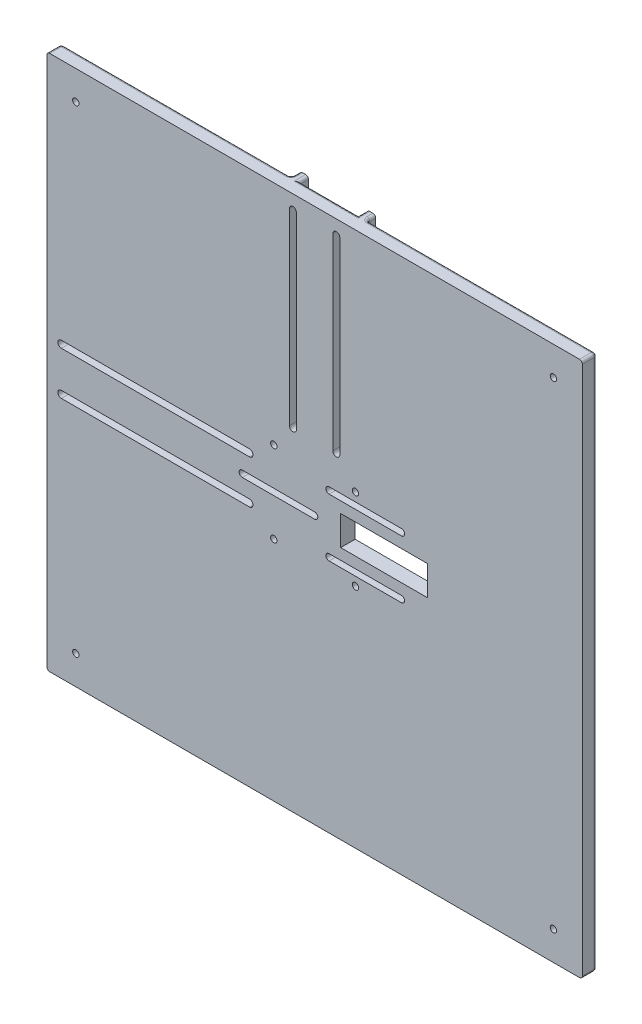
from build123d import *

# Parameters (mm, degrees)
ESQUISSE1_W              = 185
ESQUISSE1_H              = 185
BOSS_EXTRU_1_DEPTH       = 5
ESQUISSE2_W              = 70
ESQUISSE2_H              = 3
ESQUISSE2_W_2            = 3
ESQUISSE2_H_2            = 70
BOSS_EXTRU_2_DEPTH       = 3
CONG_1_R                 = 1
ENL_V_MAT_EXTRU_1_REACH  = 7
ESQUISSE4_R              = 1.1
ENL_V_MAT_EXTRU_2_DEPTH  = 6
ENL_V_MAT_EXTRU_3_REACH  = 7
ENL_V_MAT_EXTRU_5_REACH  = 10
ENL_V_MAT_EXTRU_7_REACH  = 7
ESQUISSE11_W             = 30
ESQUISSE11_H             = 10.2
ESQUISSE12_W             = 31
ESQUISSE12_H             = 4.3
ENL_V_MAT_EXTRU_9_DEPTH  = 2
CONG_2_R                 = 0.5
ENL_V_MAT_EXTRU_10_DEPTH = 3


with BuildPart() as part:
    # Esquisse1 → Boss.-Extru.1 (new body)
    with BuildSketch(Plane.XY):
        Rectangle(ESQUISSE1_W, ESQUISSE1_H)
    extrude(amount=BOSS_EXTRU_1_DEPTH)

    # Esquisse2 → Boss.-Extru.2 (add)
    with BuildSketch(Plane(origin=(0, 0, 0), x_dir=(-1, 0, 0), z_dir=(0, 0, -1))):
        with Locations((57.5, 11.6)):
            Rectangle(ESQUISSE2_W, ESQUISSE2_H)
        with Locations((57.5, -11.6)):
            Rectangle(ESQUISSE2_W, ESQUISSE2_H)
        with Locations((11.6, 57.5)):
            Rectangle(ESQUISSE2_W_2, ESQUISSE2_H_2)
        with Locations((-11.6, 57.5)):
            Rectangle(ESQUISSE2_W_2, ESQUISSE2_H_2)
    extrude(amount=BOSS_EXTRU_2_DEPTH)

    # Congé1
    cong_1_edges = [part.edges().sort_by_distance(p)[0] for p in [
        (0, 92.5, 0),
        (11.6, 22.5, 0),
        (13.1, 22.5, -1.5),
        (10.1, 92.5, -1.5),
        (13.1, 57.5, 0),
        (13.1, 92.5, -1.5),
        (-92.5, 0, 0),
        (-57.5, 13.1, 0),
        (-92.5, 13.1, -1.5),
        (-22.5, 11.6, 0),
        (-22.5, 13.1, -1.5),
        (-92.5, 10.1, -1.5),
        (-92.5, -52.8, 0),
        (-92.5, -13.1, -1.5),
        (-92.5, -10.1, -1.5),
        (-22.5, -11.6, 0),
        (-57.5, -13.1, 0),
        (-22.5, -13.1, -1.5),
        (-52.8, 92.5, 0),
        (-11.6, 22.5, 0),
        (-13.1, 57.5, 0),
        (-13.1, 22.5, -1.5),
        (-13.1, 92.5, -1.5),
        (-10.1, 92.5, -1.5),
        (52.8, 92.5, 0),
        (92.5, 0, 0),
        (0, -92.5, 0),
        (-92.5, 52.8, 0),
        (-92.5, 92.5, 2.5),
        (92.5, 92.5, 2.5),
        (92.5, -92.5, 2.5),
        (-92.5, -92.5, 2.5),
    ]]
    fillet(cong_1_edges, radius=CONG_1_R)

    # Esquisse4 → Enlèv. mat.-Extru.1 (cut, up to next)
    with BuildSketch(Plane(origin=(0, 0, 0), x_dir=(-1, 0, 0), z_dir=(0, 0, -1)), mode=Mode.PRIVATE) as enl_v_mat_extru_1_sk1:
        with Locations((-14.1, 14.1)):
            Circle(ESQUISSE4_R)
    enl_v_mat_extru_1_tool1 = extrude(enl_v_mat_extru_1_sk1.sketch, amount=-ENL_V_MAT_EXTRU_1_REACH, mode=Mode.PRIVATE) & part.part
    add(enl_v_mat_extru_1_tool1.solids().sort_by_distance((14.1, 14.1, 0))[0], mode=Mode.SUBTRACT)
    # Esquisse4 → Enlèv. mat.-Extru.1 (cut, up to next)
    with BuildSketch(Plane(origin=(0, 0, 0), x_dir=(-1, 0, 0), z_dir=(0, 0, -1)), mode=Mode.PRIVATE) as enl_v_mat_extru_1_sk2:
        with Locations((14.1, 14.1)):
            Circle(ESQUISSE4_R)
    enl_v_mat_extru_1_tool2 = extrude(enl_v_mat_extru_1_sk2.sketch, amount=-ENL_V_MAT_EXTRU_1_REACH, mode=Mode.PRIVATE) & part.part
    add(enl_v_mat_extru_1_tool2.solids().sort_by_distance((-14.1, 14.1, 0))[0], mode=Mode.SUBTRACT)
    # Esquisse4 → Enlèv. mat.-Extru.1 (cut, up to next)
    with BuildSketch(Plane(origin=(0, 0, 0), x_dir=(-1, 0, 0), z_dir=(0, 0, -1)), mode=Mode.PRIVATE) as enl_v_mat_extru_1_sk3:
        with Locations((14.1, -14.1)):
            Circle(ESQUISSE4_R)
    enl_v_mat_extru_1_tool3 = extrude(enl_v_mat_extru_1_sk3.sketch, amount=-ENL_V_MAT_EXTRU_1_REACH, mode=Mode.PRIVATE) & part.part
    add(enl_v_mat_extru_1_tool3.solids().sort_by_distance((-14.1, -14.1, 0))[0], mode=Mode.SUBTRACT)
    # Esquisse4 → Enlèv. mat.-Extru.1 (cut, up to next)
    with BuildSketch(Plane(origin=(0, 0, 0), x_dir=(-1, 0, 0), z_dir=(0, 0, -1)), mode=Mode.PRIVATE) as enl_v_mat_extru_1_sk4:
        with Locations((-14.1, -14.1)):
            Circle(ESQUISSE4_R)
    enl_v_mat_extru_1_tool4 = extrude(enl_v_mat_extru_1_sk4.sketch, amount=-ENL_V_MAT_EXTRU_1_REACH, mode=Mode.PRIVATE) & part.part
    add(enl_v_mat_extru_1_tool4.solids().sort_by_distance((14.1, -14.1, 0))[0], mode=Mode.SUBTRACT)
    # Esquisse4 → Enlèv. mat.-Extru.1 (cut, up to next)
    with BuildSketch(Plane(origin=(0, 0, 0), x_dir=(-1, 0, 0), z_dir=(0, 0, -1)), mode=Mode.PRIVATE) as enl_v_mat_extru_1_sk5:
        with Locations((-82.5, -82.5)):
            Circle(ESQUISSE4_R)
    enl_v_mat_extru_1_tool5 = extrude(enl_v_mat_extru_1_sk5.sketch, amount=-ENL_V_MAT_EXTRU_1_REACH, mode=Mode.PRIVATE) & part.part
    add(enl_v_mat_extru_1_tool5.solids().sort_by_distance((82.5, -82.5, 0))[0], mode=Mode.SUBTRACT)
    # Esquisse4 → Enlèv. mat.-Extru.1 (cut, up to next)
    with BuildSketch(Plane(origin=(0, 0, 0), x_dir=(-1, 0, 0), z_dir=(0, 0, -1)), mode=Mode.PRIVATE) as enl_v_mat_extru_1_sk6:
        with Locations((-82.5, 82.5)):
            Circle(ESQUISSE4_R)
    enl_v_mat_extru_1_tool6 = extrude(enl_v_mat_extru_1_sk6.sketch, amount=-ENL_V_MAT_EXTRU_1_REACH, mode=Mode.PRIVATE) & part.part
    add(enl_v_mat_extru_1_tool6.solids().sort_by_distance((82.5, 82.5, 0))[0], mode=Mode.SUBTRACT)
    # Esquisse4 → Enlèv. mat.-Extru.1 (cut, up to next)
    with BuildSketch(Plane(origin=(0, 0, 0), x_dir=(-1, 0, 0), z_dir=(0, 0, -1)), mode=Mode.PRIVATE) as enl_v_mat_extru_1_sk7:
        with Locations((82.5, -82.5)):
            Circle(ESQUISSE4_R)
    enl_v_mat_extru_1_tool7 = extrude(enl_v_mat_extru_1_sk7.sketch, amount=-ENL_V_MAT_EXTRU_1_REACH, mode=Mode.PRIVATE) & part.part
    add(enl_v_mat_extru_1_tool7.solids().sort_by_distance((-82.5, -82.5, 0))[0], mode=Mode.SUBTRACT)
    # Esquisse4 → Enlèv. mat.-Extru.1 (cut, up to next)
    with BuildSketch(Plane(origin=(0, 0, 0), x_dir=(-1, 0, 0), z_dir=(0, 0, -1)), mode=Mode.PRIVATE) as enl_v_mat_extru_1_sk8:
        with Locations((82.5, 82.5)):
            Circle(ESQUISSE4_R)
    enl_v_mat_extru_1_tool8 = extrude(enl_v_mat_extru_1_sk8.sketch, amount=-ENL_V_MAT_EXTRU_1_REACH, mode=Mode.PRIVATE) & part.part
    add(enl_v_mat_extru_1_tool8.solids().sort_by_distance((-82.5, 82.5, 0))[0], mode=Mode.SUBTRACT)

    # Esquisse5 → Enlèv. mat.-Extru.2 (cut, through all)
    with BuildSketch(Plane(origin=(0, 0, 0), x_dir=(-1, 0, 0), z_dir=(0, 0, -1))):
        with BuildLine():
            Line((-6.3, 87.5), (-6.3, 22.5))
            ThreePointArc((-6.3, 22.5), (-7.5, 21.3), (-8.7, 22.5))
            Line((-8.7, 22.5), (-8.7, 87.5))
            ThreePointArc((-8.7, 87.5), (-7.5, 88.7), (-6.3, 87.5))
        make_face()
        with BuildLine():
            Line((8.7, 87.5), (8.7, 22.5))
            ThreePointArc((8.7, 22.5), (7.5, 21.3), (6.3, 22.5))
            Line((6.3, 22.5), (6.3, 87.5))
            ThreePointArc((6.3, 87.5), (7.5, 88.7), (8.7, 87.5))
        make_face()
    extrude(amount=-ENL_V_MAT_EXTRU_2_DEPTH, mode=Mode.SUBTRACT)

    # Esquisse6 → Enlèv. mat.-Extru.3 (cut, up to next)
    with BuildSketch(Plane(origin=(0, 0, 0), x_dir=(-1, 0, 0), z_dir=(0, 0, -1)), mode=Mode.PRIVATE) as enl_v_mat_extru_3_sk1:
        with BuildLine():
            Line((87.5, -8.7), (22.5, -8.7))
            ThreePointArc((22.5, -8.7), (21.3, -7.5), (22.5, -6.3))
            Line((22.5, -6.3), (87.5, -6.3))
            ThreePointArc((87.5, -6.3), (88.7, -7.5), (87.5, -8.7))
        make_face()
    enl_v_mat_extru_3_tool1 = extrude(enl_v_mat_extru_3_sk1.sketch, amount=-ENL_V_MAT_EXTRU_3_REACH, mode=Mode.PRIVATE) & part.part
    add(enl_v_mat_extru_3_tool1.solids().sort_by_distance((-55, -7.5, 0))[0], mode=Mode.SUBTRACT)
    # Esquisse6 → Enlèv. mat.-Extru.3 (cut, up to next)
    with BuildSketch(Plane(origin=(0, 0, 0), x_dir=(-1, 0, 0), z_dir=(0, 0, -1)), mode=Mode.PRIVATE) as enl_v_mat_extru_3_sk2:
        with BuildLine():
            Line((22.5, 8.7), (87.5, 8.7))
            ThreePointArc((87.5, 8.7), (88.7, 7.5), (87.5, 6.3))
            Line((87.5, 6.3), (22.5, 6.3))
            ThreePointArc((22.5, 6.3), (21.3, 7.5), (22.5, 8.7))
        make_face()
    enl_v_mat_extru_3_tool2 = extrude(enl_v_mat_extru_3_sk2.sketch, amount=-ENL_V_MAT_EXTRU_3_REACH, mode=Mode.PRIVATE) & part.part
    add(enl_v_mat_extru_3_tool2.solids().sort_by_distance((-55, 7.5, 0))[0], mode=Mode.SUBTRACT)

    # Esquisse9 → Enlèv. mat.-Extru.5 (cut, up to next)
    with BuildSketch(Plane.XY.offset(5), mode=Mode.PRIVATE) as enl_v_mat_extru_5_sk1:
        with BuildLine():
            Line((-25, 1.1), (0, 1.1))
            ThreePointArc((0, 1.1), (1.1, 0), (0, -1.1))
            Line((0, -1.1), (-25, -1.1))
            ThreePointArc((-25, -1.1), (-26.1, 0), (-25, 1.1))
        make_face()
    enl_v_mat_extru_5_tool1 = extrude(enl_v_mat_extru_5_sk1.sketch, amount=-ENL_V_MAT_EXTRU_5_REACH, mode=Mode.PRIVATE) & part.part
    add(enl_v_mat_extru_5_tool1.solids().sort_by_distance((-12.5, 0, 5))[0], mode=Mode.SUBTRACT)
    # Esquisse9 → Enlèv. mat.-Extru.5 (cut, up to next)
    with BuildSketch(Plane.XY.offset(5), mode=Mode.PRIVATE) as enl_v_mat_extru_5_sk2:
        with BuildLine():
            Line((5, 11.1), (30, 11.1))
            ThreePointArc((30, 11.1), (31.1, 10), (30, 8.9))
            Line((30, 8.9), (5, 8.9))
            ThreePointArc((5, 8.9), (3.9, 10), (5, 11.1))
        make_face()
    enl_v_mat_extru_5_tool2 = extrude(enl_v_mat_extru_5_sk2.sketch, amount=-ENL_V_MAT_EXTRU_5_REACH, mode=Mode.PRIVATE) & part.part
    add(enl_v_mat_extru_5_tool2.solids().sort_by_distance((17.5, 10, 5))[0], mode=Mode.SUBTRACT)
    # Esquisse9 → Enlèv. mat.-Extru.5 (cut, up to next)
    with BuildSketch(Plane.XY.offset(5), mode=Mode.PRIVATE) as enl_v_mat_extru_5_sk3:
        with BuildLine():
            Line((5, -8.9), (30, -8.9))
            ThreePointArc((30, -8.9), (31.1, -10), (30, -11.1))
            Line((30, -11.1), (5, -11.1))
            ThreePointArc((5, -11.1), (3.9, -10), (5, -8.9))
        make_face()
    enl_v_mat_extru_5_tool3 = extrude(enl_v_mat_extru_5_sk3.sketch, amount=-ENL_V_MAT_EXTRU_5_REACH, mode=Mode.PRIVATE) & part.part
    add(enl_v_mat_extru_5_tool3.solids().sort_by_distance((17.5, -10, 5))[0], mode=Mode.SUBTRACT)

    # Esquisse11 → Enlèv. mat.-Extru.7 (cut, up to next)
    with BuildSketch(Plane(origin=(0, 0, 0), x_dir=(-1, 0, 0), z_dir=(0, 0, -1)), mode=Mode.PRIVATE) as enl_v_mat_extru_7_sk1:
        with Locations((-24, 0)):
            Rectangle(ESQUISSE11_W, ESQUISSE11_H)
    enl_v_mat_extru_7_tool1 = extrude(enl_v_mat_extru_7_sk1.sketch, amount=-ENL_V_MAT_EXTRU_7_REACH, mode=Mode.PRIVATE) & part.part
    add(enl_v_mat_extru_7_tool1.solids().sort_by_distance((24, 0, 0))[0], mode=Mode.SUBTRACT)

    # Esquisse12 → Enlèv. mat.-Extru.9 (cut)
    with BuildSketch(Plane(origin=(0, 0, 0), x_dir=(-1, 0, 0), z_dir=(0, 0, -1))):
        with Locations((-17.5, 9.95)):
            Rectangle(ESQUISSE12_W, ESQUISSE12_H)
        with Locations((-17.5, -10.05)):
            Rectangle(ESQUISSE12_W, ESQUISSE12_H)
        with Locations((12.5, -0.05)):
            Rectangle(ESQUISSE12_W, ESQUISSE12_H)
    extrude(amount=-ENL_V_MAT_EXTRU_9_DEPTH, mode=Mode.SUBTRACT)

    # Congé2
    cong_2_edges = [part.edges().sort_by_distance(p)[0] for p in [
        (33, 7.8, 1),
        (33, 12.1, 1),
        (2, 12.1, 1),
        (33, -12.2, 1),
        (33, -7.9, 1),
        (2, -7.9, 1),
        (2, -12.2, 1),
        (3, -2.2, 1),
        (3, 2.1, 1),
        (-28, 2.1, 1),
        (-28, -2.2, 1),
    ]]
    fillet(cong_2_edges, radius=CONG_2_R)

    # Esquisse13 → Enlèv. mat.-Extru.10 (cut)
    with BuildSketch(Plane(origin=(0, 0, 0), x_dir=(-1, 0, 0), z_dir=(0, 0, -1))):
        Polygon((-80, -82.5), (-81.25, -80.334936491), (-83.75, -80.334936491), (-85, -82.5), (-83.75, -84.665063509), (-81.25, -84.665063509), align=None)
        Polygon((83.75, -84.665063509), (85, -82.5), (83.75, -80.334936491), (81.25, -80.334936491), (80, -82.5), (81.25, -84.665063509), align=None)
        Polygon((85, 82.5), (83.75, 84.665063509), (81.25, 84.665063509), (80, 82.5), (81.25, 80.334936491), (83.75, 80.334936491), align=None)
        Polygon((-80, 82.5), (-81.25, 84.665063509), (-83.75, 84.665063509), (-85, 82.5), (-83.75, 80.334936491), (-81.25, 80.334936491), align=None)
    extrude(amount=-ENL_V_MAT_EXTRU_10_DEPTH, mode=Mode.SUBTRACT)


solid = part.part
